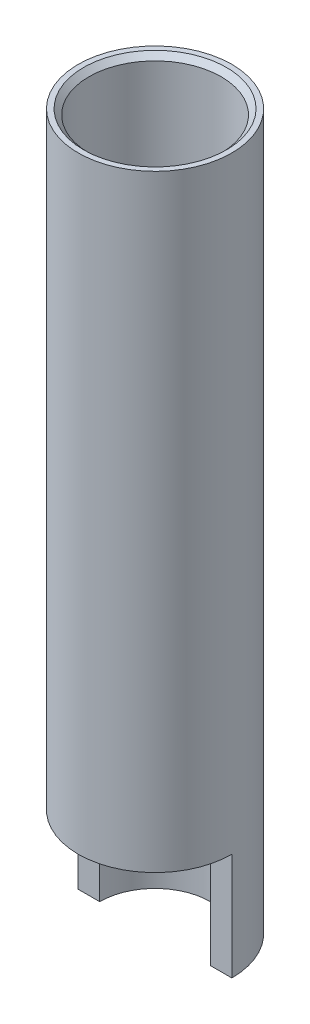
from build123d import *

# Parameters (mm, degrees)
ESBO_O3_W             = 4.788650246
ESBO_O3_H             = 2.452019704
CORTE_EXTRUS_O4_DEPTH = 3
CHANFRO1_SIZE         = 0.15


with BuildPart() as part:
    # Esboço1 → Revolução1 (revolve)
    with BuildSketch(Plane.XY):
        Polygon((0, 4), (0, 10), (1.85, 11), (1.85, 20), (2.15, 20), (2.15, 0), (1.55, 0), (1.55, 3), align=None)
    revolve(axis=Axis((0, 4, 0), (0, 1, 0)))

    # Esboço3 → Corte-extrusão4 (cut)
    with BuildSketch(Plane.XZ):
        with Locations((0, 1.226009852)):
            Rectangle(ESBO_O3_W, ESBO_O3_H)
    extrude(amount=-CORTE_EXTRUS_O4_DEPTH, mode=Mode.SUBTRACT)

    # Chanfro1
    chanfro1_edges = [part.edges().sort_by_distance(p)[0] for p in [
        (-1.85, 20, 0),
    ]]
    chamfer(chanfro1_edges, length=CHANFRO1_SIZE)


solid = part.part
